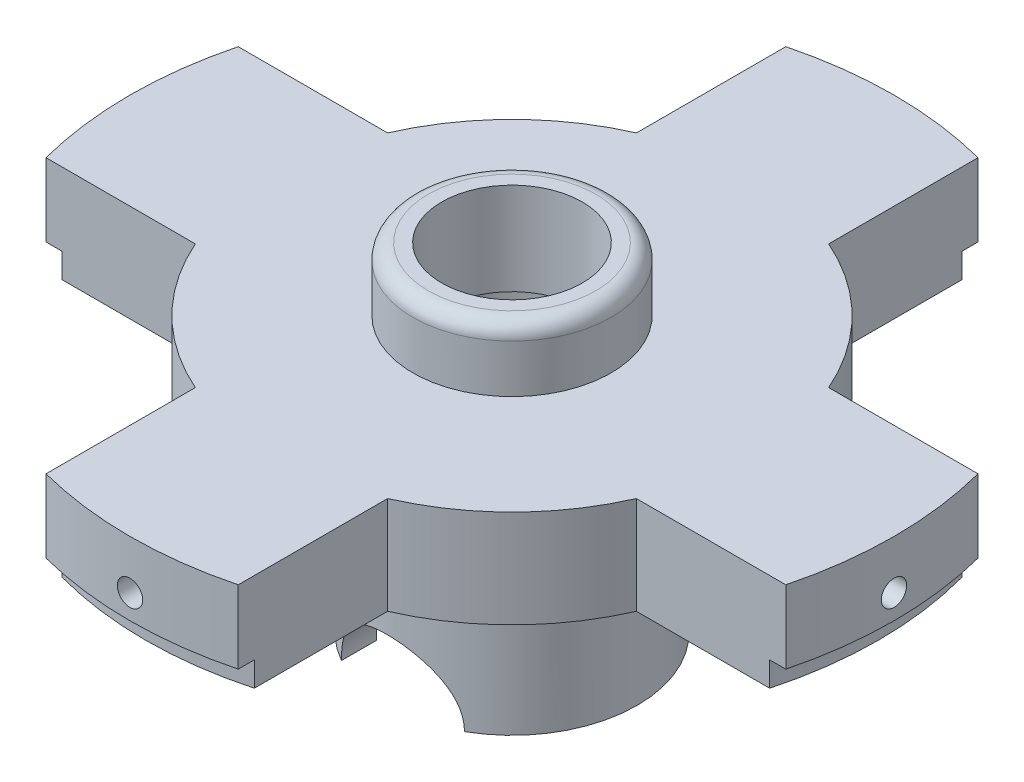
from build123d import *

# Parameters (mm, degrees)
CUT_EXTRUDE3_DEPTH      = 17.28
CUT_EXTRUDE3_DEPTH_BACK = 17.28
SKETCH3_R               = 1.125
CUT_EXTRUDE4_DEPTH      = 17.2800001
CIRPATTERN1_COUNT       = 3
FILLET4_R               = 2
SKETCH4_R               = 16.28
BOSS_EXTRUDE1_DEPTH     = 12.7
SKETCH5_R               = 1.6425
CUT_EXTRUDE5_DEPTH      = 50.7
CUT_EXTRUDE6_DEPTH      = 3.2004
CIRPATTERN2_COUNT       = 4
CIRPATTERN3_COUNT       = 4


with BuildPart() as part:
    # Sketch1 → Revolve1 (revolve)
    with BuildSketch(Plane.XY, mode=Mode.PRIVATE) as revolve1_sk:
        Polygon((9.14, 44), (12.89, 44), (12.89, 35.75), (16.28, 35.75), (16.28, 0), (12.53, 0), (12.53, 32), (9.14, 32), align=None)
    revolve(revolve1_sk.sketch.rotate(Axis((0, 0, 0), (0, 1, 0)), 90), axis=Axis((0, 0, 0), (0, 1, 0)))  # turned: the seam where the file's is

    # Sketch2 → Cut-Extrude3 (cut, two sides)
    with BuildSketch(Plane.XY) as cut_extrude3_sk:
        with BuildLine():
            Line((-8, 0), (8, 0))
            ThreePointArc((8, 0), (0, 8), (-8, 0))
        make_face()
    extrude(amount=CUT_EXTRUDE3_DEPTH, mode=Mode.SUBTRACT)
    extrude(cut_extrude3_sk.sketch, amount=-CUT_EXTRUDE3_DEPTH_BACK, mode=Mode.SUBTRACT)

    # Sketch3 → Cut-Extrude4 (cut, through all)
    with BuildSketch(Plane(origin=(0, 0, 0), x_dir=(0, 0, -1), z_dir=(1, 0, 0))):
        with Locations((0, 14.3)):
            Circle(SKETCH3_R)
    cut_extrude4 = extrude(amount=-CUT_EXTRUDE4_DEPTH, mode=Mode.SUBTRACT)

    # CirPattern1: Cut-Extrude4 ×3 about axis
    cirpattern1_axis = Axis((0, 46.725, 0), (0, -1, 0))
    for i in range(1, CIRPATTERN1_COUNT):
        add(cut_extrude4.rotate(cirpattern1_axis, i * 360 / CIRPATTERN1_COUNT), mode=Mode.SUBTRACT)

    # Fillet4
    fillet4_edges = [part.edges().sort_by_distance(p)[0] for p in [
        (0, 44, 12.89),
    ]]
    fillet(fillet4_edges, radius=FILLET4_R)

    # Sketch4 → Boss-Extrude1 (add)
    with BuildSketch(Plane(origin=(0, 35.75, 0), x_dir=(1, 0, 0), z_dir=(0, 1, 0))):
        with BuildLine():
            Line((-12.5, 48.102390793), (-12.5, 28.673827788))
            ThreePointArc((-12.5, 28.673827788), (-22.118300116, 22.118300116), (-28.673827788, 12.5))
            Line((-28.673827788, 12.5), (-48.102390793, 12.5))
            ThreePointArc((-48.102390793, 12.5), (-49.7, 0), (-48.102390793, -12.5))
            Line((-48.102390793, -12.5), (-28.673827788, -12.5))
            ThreePointArc((-28.673827788, -12.5), (-22.118300116, -22.118300116), (-12.5, -28.673827788))
            Line((-12.5, -28.673827788), (-12.5, -48.102390793))
            ThreePointArc((-12.5, -48.102390793), (0, -49.7), (12.5, -48.102390793))
            Line((12.5, -48.102390793), (12.5, -28.673827788))
            ThreePointArc((12.5, -28.673827788), (22.118300116, -22.118300116), (28.673827788, -12.5))
            Line((28.673827788, -12.5), (48.102390793, -12.5))
            ThreePointArc((48.102390793, -12.5), (49.7, 0), (48.102390793, 12.5))
            Line((48.102390793, 12.5), (28.673827788, 12.5))
            ThreePointArc((28.673827788, 12.5), (22.118300116, 22.118300116), (12.5, 28.673827788))
            Line((12.5, 28.673827788), (12.5, 48.102390793))
            ThreePointArc((12.5, 48.102390793), (0, 49.7), (-12.5, 48.102390793))
        make_face()
        with Locations(Location((0, 0, 0), (0, 0, 119.432673442))):  # turned: the seam where the file's is
            Circle(SKETCH4_R, mode=Mode.SUBTRACT)
    extrude(amount=-BOSS_EXTRUDE1_DEPTH)

    # Sketch5 → Cut-Extrude5 (cut, through all)
    with BuildSketch(Plane.XY):
        with Locations(Location((0, 29.4, 0), (0, 0, 90))):  # turned: the seam where the file's is
            Circle(SKETCH5_R)
    cut_extrude5 = extrude(amount=-CUT_EXTRUDE5_DEPTH, mode=Mode.SUBTRACT)

    # Sketch6 → Cut-Extrude6 (cut)
    with BuildSketch(Plane.XZ.offset(-23.05)):
        with BuildLine():
            Line((-12.5, 48.102390793), (-12.5, 46.007125807))
            ThreePointArc((-12.5, 46.007125807), (0, 47.675), (12.5, 46.007125807))
            Line((12.5, 46.007125807), (12.5, 48.102390793))
            ThreePointArc((12.5, 48.102390793), (0, 49.7), (-12.5, 48.102390793))
        make_face()
    cut_extrude6 = extrude(amount=-CUT_EXTRUDE6_DEPTH, mode=Mode.SUBTRACT)

    # CirPattern2: Cut-Extrude5 ×4 about axis
    cirpattern2_axis = Axis((0, 46.725, 0), (0, -1, 0))
    for i in range(1, CIRPATTERN2_COUNT):
        add(cut_extrude5.rotate(cirpattern2_axis, i * 360 / CIRPATTERN2_COUNT), mode=Mode.SUBTRACT)

    # CirPattern3: Cut-Extrude6 ×4 about axis
    cirpattern3_axis = Axis((0, 46.725, 0), (0, -1, 0))
    for i in range(1, CIRPATTERN3_COUNT):
        add(cut_extrude6.rotate(cirpattern3_axis, i * 360 / CIRPATTERN3_COUNT), mode=Mode.SUBTRACT)


solid = part.part
